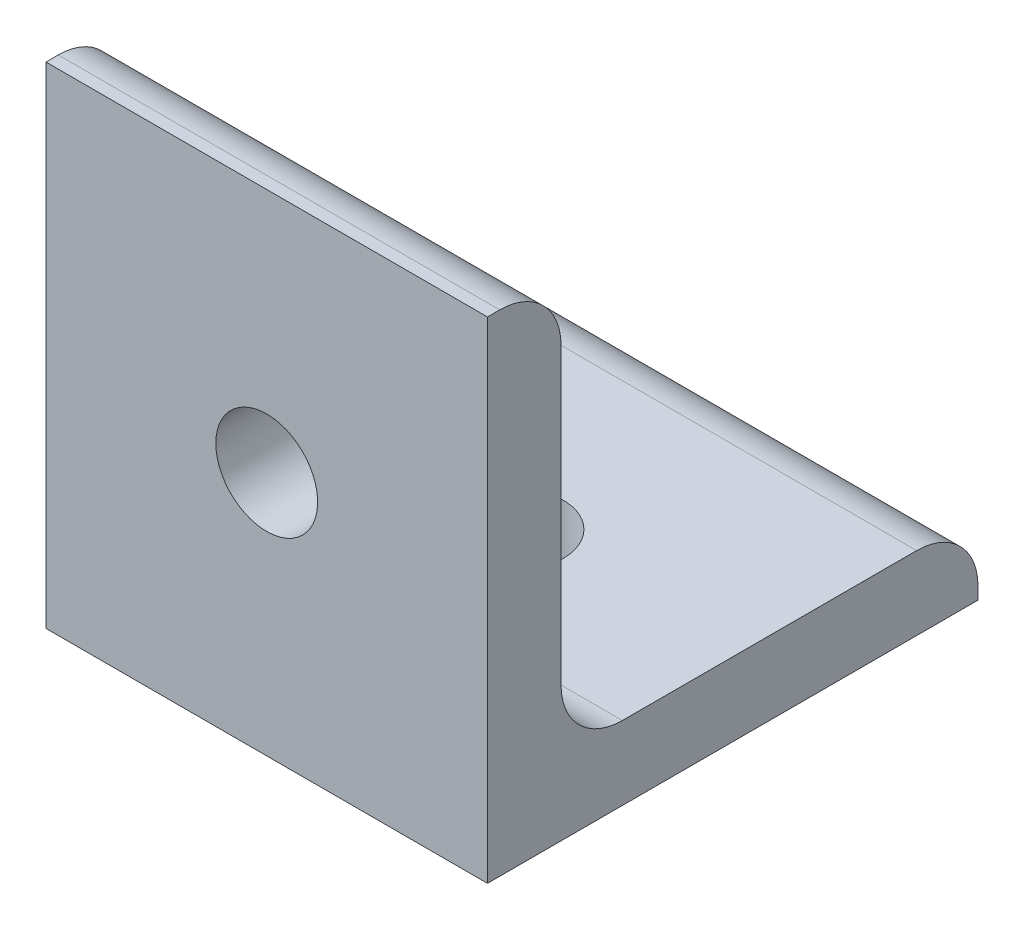
from build123d import *

# Parameters (mm, degrees)
BOSS_EXTRUDE1_DEPTH = 18
SKETCH2_R           = 4.15
CUT_EXTRUDE1_DEPTH  = 7
SKETCH3_R           = 4.15
CUT_EXTRUDE2_DEPTH  = 7
FILLET1_R           = 5


with BuildPart() as part:
    # Sketch1 → Boss-Extrude1 (new body, symmetric)
    with BuildSketch(Plane(origin=(0, 0, 0), x_dir=(0, 0, -1), z_dir=(1, 0, 0))):
        Polygon((0, 40), (0, 0), (40, 0), (40, 6), (6, 6), (6, 40), align=None)
    extrude(amount=BOSS_EXTRUDE1_DEPTH, both=True)

    # Sketch2 → Cut-Extrude1 (cut, through all)
    with BuildSketch(Plane(origin=(0, 6, 0), x_dir=(1, 0, 0), z_dir=(0, 1, 0))):
        with Locations((0, 20)):
            Circle(SKETCH2_R)
    extrude(amount=-CUT_EXTRUDE1_DEPTH, mode=Mode.SUBTRACT)

    # Sketch3 → Cut-Extrude2 (cut, through all)
    with BuildSketch(Plane(origin=(0, 0, -6), x_dir=(-1, 0, 0), z_dir=(0, 0, -1))):
        with Locations((0, 20)):
            Circle(SKETCH3_R)
    extrude(amount=-CUT_EXTRUDE2_DEPTH, mode=Mode.SUBTRACT)

    # Fillet1
    fillet1_edges = [part.edges().sort_by_distance(p)[0] for p in [
        (0, 40, -6),
        (0, 6, -6),
        (0, 6, -40),
    ]]
    fillet(fillet1_edges, radius=FILLET1_R)


solid = part.part
